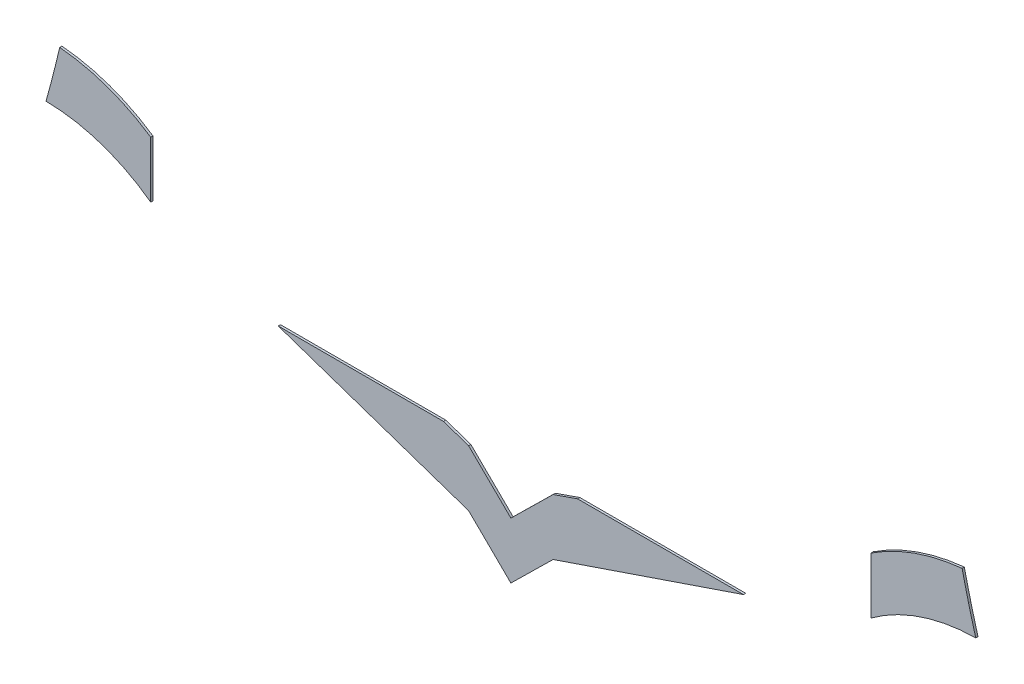
from build123d import *

# Parameters (mm, degrees)
SALIENTE_EXTRUIR1_DEPTH   = 0.1
SALIENTE_EXTRUIR1_2_DEPTH = 0.1
SALIENTE_EXTRUIR1_3_DEPTH = 0.1


with BuildPart() as part:
    # Model → Saliente-Extruir1 (new body)
    with BuildSketch(Plane.XY):
        with BuildLine():
            ThreePointArc((16.253690147, -13.180235977), (18.70290977, -13.595394577), (20.906414144, -14.742391482))
            Line((20.906414144, -14.742391482), (20.906176461, -12.240206894))
            ThreePointArc((20.906176461, -12.240206894), (18.975913125, -11.265172682), (16.862658207, -10.806084555))
            ThreePointArc((16.862658207, -10.806084555), (16.572539002, -11.996844833), (16.253690147, -13.180235977))
        make_face()
    extrude(amount=SALIENTE_EXTRUIR1_DEPTH)


with BuildPart() as body_2:
    # Model → Saliente-Extruir1 2 (new body)
    with BuildSketch(Plane.XY):
        Polygon((47.239091143, -16.670761499), (38.78228857, -19.550227381), (36.907167402, -21.394207383), (35.031633608, -19.550405519), (26.571674165, -16.670761499), (33.916059279, -16.670761499), (35.031396133, -17.05040553), (36.906929927, -18.894207394), (38.78228857, -17.050227381), (39.870796767, -16.670761499), align=None)
    extrude(amount=SALIENTE_EXTRUIR1_2_DEPTH)


with BuildPart() as body_3:
    # Model → Saliente-Extruir1 3 (new body)
    with BuildSketch(Plane.XY):
        with BuildLine():
            ThreePointArc((56.952895616, -10.80397792), (54.843195929, -11.27662203), (52.907051257, -12.238687012))
            Line((52.907051257, -12.238687012), (52.907051257, -14.740871612))
            ThreePointArc((52.907051257, -14.740871612), (55.110446668, -13.593665401), (57.559626843, -13.178274152))
            ThreePointArc((57.559626843, -13.178274152), (57.395729395, -12.582964534), (57.239261898, -11.985659053))
            ThreePointArc((57.239261898, -11.985659053), (57.092497922, -11.395686259), (56.952895616, -10.80397792))
        make_face()
    extrude(amount=SALIENTE_EXTRUIR1_3_DEPTH)


solid = Compound([part.part, body_2.part, body_3.part])
